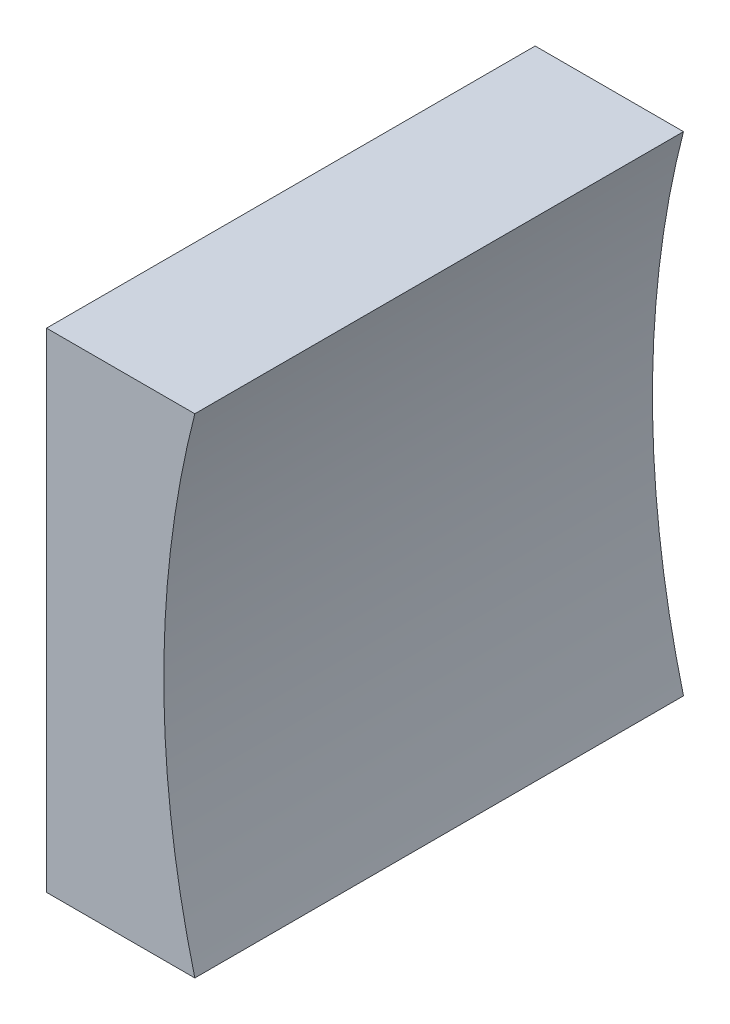
from build123d import *

# Parameters (mm, degrees)
EXTRUDE_1_DEPTH = 12.5


with BuildPart() as part:
    # 草图1 → 凸台-拉伸1 (new body)
    with BuildSketch(Plane.XY):
        with BuildLine():
            Line((142.353567816, 33.428964634), (142.353567816, 39.678964634))
            Line((142.353567816, 39.678964634), (146.147421902, 39.678964634))
            ThreePointArc((146.147421902, 39.678964634), (145.353567816, 33.428964634), (146.147421902, 27.178964634))
            Line((146.147421902, 27.178964634), (142.353567816, 27.178964634))
            Line((142.353567816, 27.178964634), (142.353567816, 33.428964634))
        make_face()
    extrude(amount=EXTRUDE_1_DEPTH)


solid = part.part
